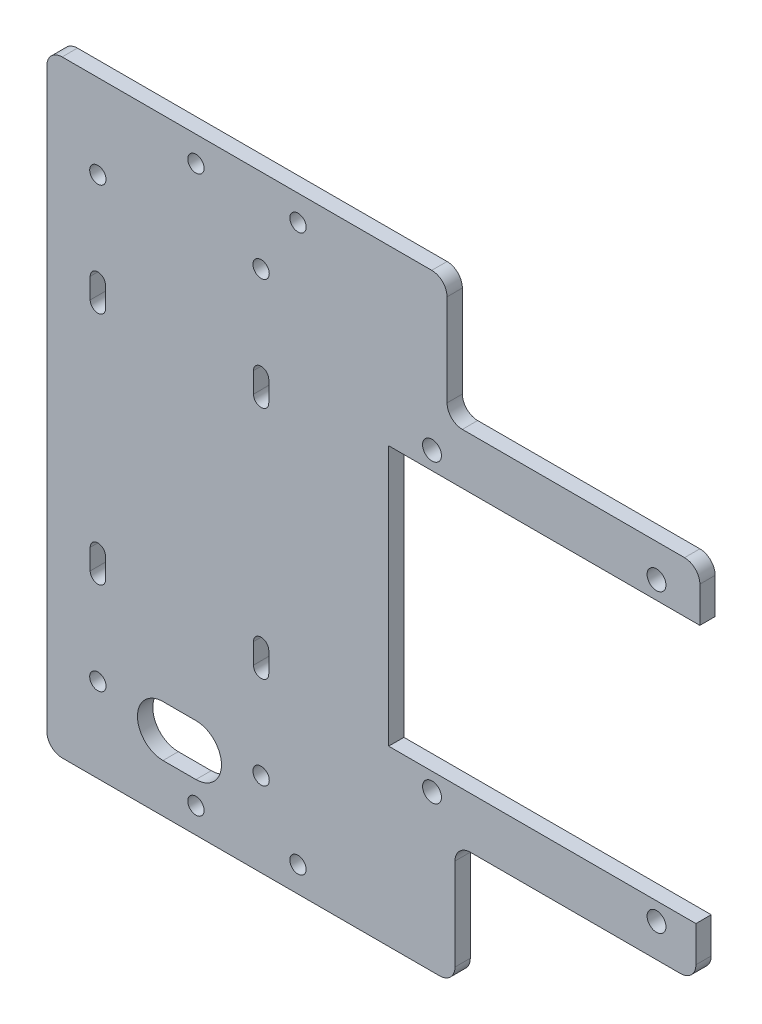
from build123d import *

# Parameters (mm, degrees)
SKETCH_1_R      = 1.6
SKETCH_1_R_2    = 1.85
EXTRUDE_1_DEPTH = 3
FILLET_1_R      = 3


with BuildPart() as part:
    # 草图1 → 凸台-拉伸1 (new body)
    with BuildSketch(Plane.XY):
        Polygon((65.759662845, 31.457301477), (53.535196603, 31.457301477), (53.535196603, -19.542698523), (64.984129087, -19.542698523), (113.759662845, -19.542698523), (113.759662845, -29.542698523), (66.535196603, -29.542698523), (66.535196603, -53.542698523), (-13.464803397, -53.542698523), (-13.464803397, 65.457301477), (64.984129087, 65.457301477), (64.984129087, 41.457301477), (114.535196603, 41.457301477), (114.535196603, 31.457301477), align=None)
        with Locations((15.759662845, 60.457301477)):
            Circle(SKETCH_1_R, mode=Mode.SUBTRACT)
        with Locations((35.759662845, 60.457301477)):
            Circle(SKETCH_1_R, mode=Mode.SUBTRACT)
        with Locations((15.759662845, -48.542698523)):
            Circle(SKETCH_1_R, mode=Mode.SUBTRACT)
        with Locations((35.759662845, -48.542698523)):
            Circle(SKETCH_1_R, mode=Mode.SUBTRACT)
        with Locations((-3.464803397, 48.957301477)):
            Circle(SKETCH_1_R, mode=Mode.SUBTRACT)
        with Locations((28.535196603, 48.957301477)):
            Circle(SKETCH_1_R, mode=Mode.SUBTRACT)
        with Locations((-3.464803397, -37.042698523)):
            Circle(SKETCH_1_R, mode=Mode.SUBTRACT)
        with Locations((28.535196603, -37.042698523)):
            Circle(SKETCH_1_R, mode=Mode.SUBTRACT)
        with Locations((62.035196603, -23.042698523)):
            Circle(SKETCH_1_R_2, mode=Mode.SUBTRACT)
        with Locations((106.035196603, -23.042698523)):
            Circle(SKETCH_1_R_2, mode=Mode.SUBTRACT)
        with Locations((62.035196603, 34.957301477)):
            Circle(SKETCH_1_R_2, mode=Mode.SUBTRACT)
        with Locations((106.035196603, 34.957301477)):
            Circle(SKETCH_1_R_2, mode=Mode.SUBTRACT)
        with BuildLine():
            Line((9.302741514, -34.092463325), (15.759662845, -34.092463325))
            ThreePointArc((15.759662845, -34.092463325), (20.759662845, -39.092463325), (15.759662845, -44.092463325))
            Line((15.759662845, -44.092463325), (9.302741514, -44.092463325))
            ThreePointArc((9.302741514, -44.092463325), (4.302741514, -39.092463325), (9.302741514, -34.092463325))
        make_face(mode=Mode.SUBTRACT)
        with BuildLine():
            Line((-1.964803397, 30.957301477), (-1.964803397, 26.957301477))
            ThreePointArc((-1.964803397, 26.957301477), (-3.464803397, 25.457301477), (-4.964803397, 26.957301477))
            Line((-4.964803397, 26.957301477), (-4.964803397, 30.957301477))
            ThreePointArc((-4.964803397, 30.957301477), (-3.464803397, 32.457301477), (-1.964803397, 30.957301477))
        make_face(mode=Mode.SUBTRACT)
        with BuildLine():
            Line((-1.964803397, -15.042698523), (-1.964803397, -19.042698523))
            ThreePointArc((-1.964803397, -19.042698523), (-3.464803397, -20.542698523), (-4.964803397, -19.042698523))
            Line((-4.964803397, -19.042698523), (-4.964803397, -15.042698523))
            ThreePointArc((-4.964803397, -15.042698523), (-3.464803397, -13.542698523), (-1.964803397, -15.042698523))
        make_face(mode=Mode.SUBTRACT)
        with BuildLine():
            Line((27.035196603, -15.042698523), (27.035196603, -19.042698523))
            ThreePointArc((27.035196603, -19.042698523), (28.535196603, -20.542698523), (30.035196603, -19.042698523))
            Line((30.035196603, -19.042698523), (30.035196603, -15.042698523))
            ThreePointArc((30.035196603, -15.042698523), (28.535196603, -13.542698523), (27.035196603, -15.042698523))
        make_face(mode=Mode.SUBTRACT)
        with BuildLine():
            Line((27.035196603, 30.957301477), (27.035196603, 26.957301477))
            ThreePointArc((27.035196603, 26.957301477), (28.535196603, 25.457301477), (30.035196603, 26.957301477))
            Line((30.035196603, 26.957301477), (30.035196603, 30.957301477))
            ThreePointArc((30.035196603, 30.957301477), (28.535196603, 32.457301477), (27.035196603, 30.957301477))
        make_face(mode=Mode.SUBTRACT)
    extrude(amount=EXTRUDE_1_DEPTH)

    # 圆角1
    fillet_1_edges = [part.edges().sort_by_distance(p)[0] for p in [
        (-13.464803397, 65.457301477, 1.5),
        (64.984129087, 65.457301477, 1.5),
        (64.984129087, 41.457301477, 1.5),
        (114.535196603, 41.457301477, 1.5),
        (113.759662845, -29.542698523, 1.5),
        (66.535196603, -29.542698523, 1.5),
        (66.535196603, -53.542698523, 1.5),
        (-13.464803397, -53.542698523, 1.5),
    ]]
    fillet(fillet_1_edges, radius=FILLET_1_R)


solid = part.part
